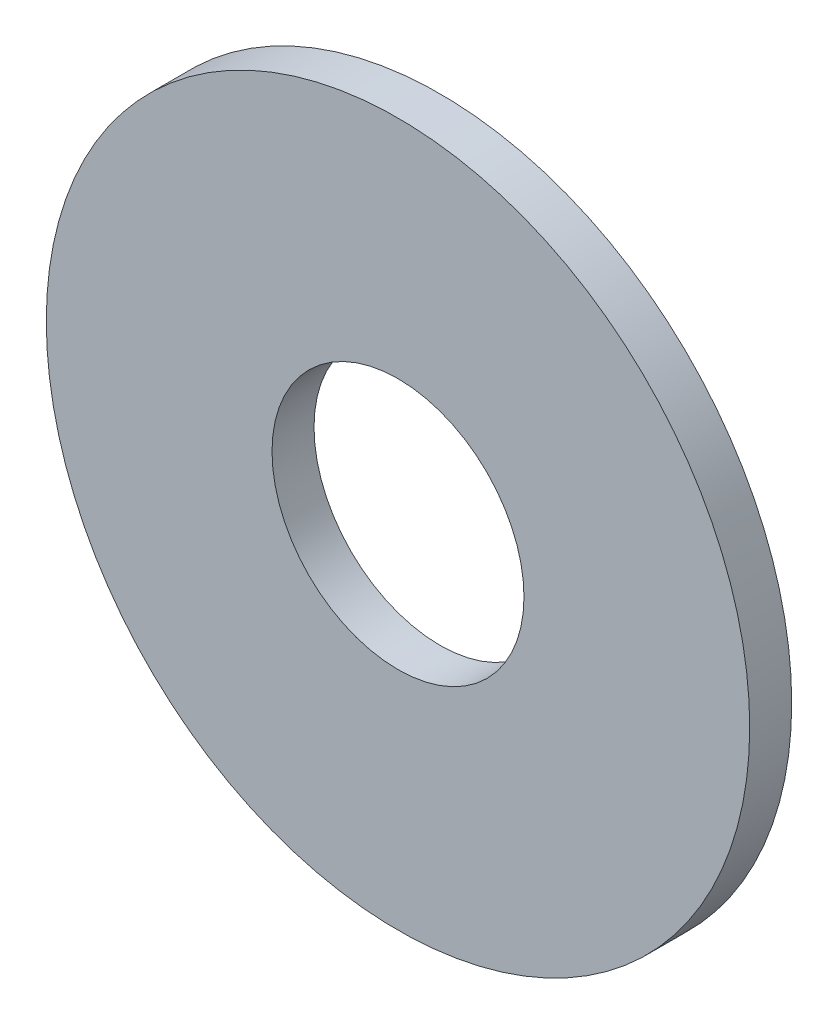
from build123d import *

# Parameters (mm, degrees)
ESQUISSE1_R          = 16.75
ESQUISSE1_R_2        = 6
BASE_EXTRUSION_DEPTH = 2


with BuildPart() as part:
    # Esquisse1 → Base-Extrusion (new body)
    with BuildSketch(Plane.XY):
        Circle(ESQUISSE1_R)
        Circle(ESQUISSE1_R_2, mode=Mode.SUBTRACT)
    extrude(amount=BASE_EXTRUSION_DEPTH)


solid = part.part
